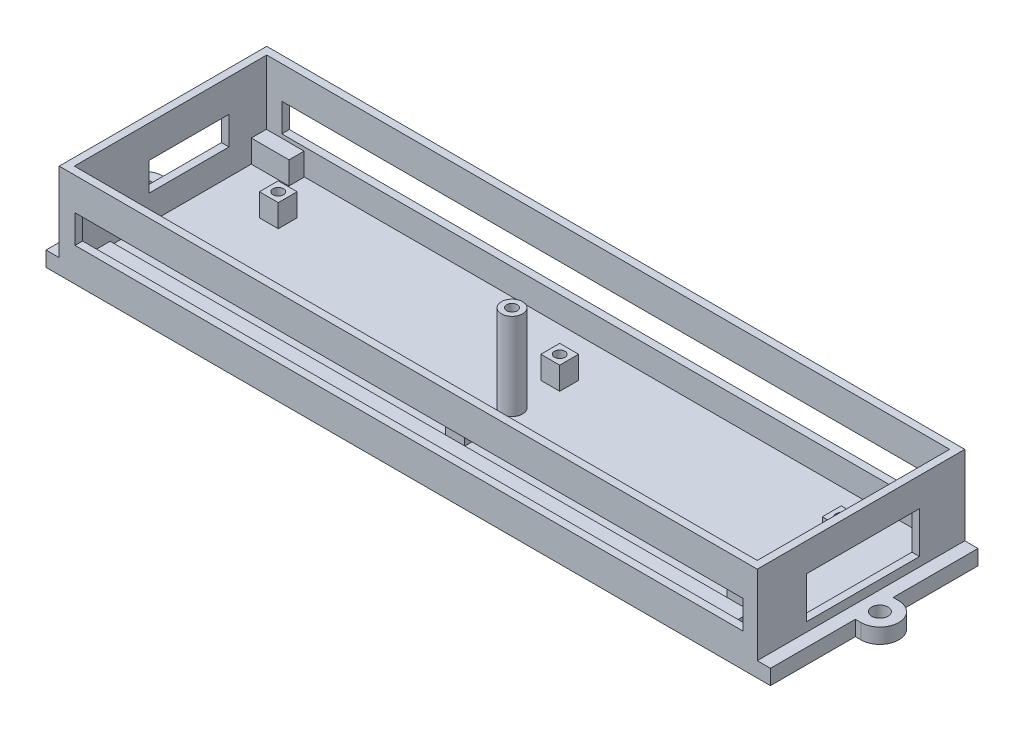
from build123d import *

# Parameters (mm, degrees)
SKETCH_1_W           = 185
SKETCH_1_H           = 55
EXTRUDE_1_DEPTH      = 25
SHELL_1_T            = -2
SKETCH_8_R           = 2.15
EXTRUDE_3_DEPTH      = 4
SKETCH_2_W           = 10
SKETCH_2_H           = 4
SKETCH_2_W_2         = 5
SKETCH_2_H_2         = 5
SKETCH_2_R           = 1.4
SKETCH_2_W_3         = 170
EXTRUDE_4_DEPTH      = 6
SKETCH_2_6_R         = 2.8
SKETCH_2_6_R_2       = 1.4
EXTRUDE_6_DEPTH      = 23
SKETCH_9_W           = 30
SKETCH_9_H           = 11
CUT_EXTRUDE_7_DEPTH  = 5
SKETCH_10_W          = 177
SKETCH_10_H          = 7.5
CUT_EXTRUDE_8_DEPTH  = 5
SKETCH_11_W          = 21.2
SKETCH_11_H          = 7.5
CUT_EXTRUDE_9_DEPTH  = 5
SKETCH_12_W          = 174
SKETCH_12_H          = 7.5
CUT_EXTRUDE_10_DEPTH = 5


with BuildPart() as part:
    # 草图1 → 凸台-拉伸1 (new body)
    with BuildSketch(Plane(origin=(0, 0, 0), x_dir=(1, 0, 0), z_dir=(0, 1, 0))):
        Rectangle(SKETCH_1_W, SKETCH_1_H)
    extrude(amount=EXTRUDE_1_DEPTH)

    # 抽壳1
    shell_1_openings = [part.faces().sort_by_distance(p)[0] for p in [
        (0, 25, 0),
    ]]
    offset(amount=SHELL_1_T, openings=shell_1_openings, kind=Kind.INTERSECTION)

    # 草图8 → 凸台-拉伸3 (add)
    # profile 1 of 2: a face of its own
    with BuildSketch(Plane.XZ):
        with BuildLine():
            Line((-97.5, 5), (-96, 5))
            Line((-96, 5), (-96, 27.5))
            Line((-96, 27.5), (-92.5, 27.5))
            Line((-92.5, 27.5), (-92.5, -27.5))
            Line((-92.5, -27.5), (-96, -27.5))
            Line((-96, -27.5), (-96, -5))
            Line((-96, -5), (-97.5, -5))
            ThreePointArc((-97.5, -5), (-102.5, 0), (-97.5, 5))
        make_face()
        with Locations((-97.5, 0)):
            Circle(SKETCH_8_R, mode=Mode.SUBTRACT)
    # profile 2 of 2: a face of its own
    with BuildSketch(Plane.XZ):
        with BuildLine():
            Line((97.5, -5), (96, -5))
            Line((96, -5), (96, -27.5))
            Line((96, -27.5), (92.5, -27.5))
            Line((92.5, -27.5), (92.5, -5))
            Line((92.5, -5), (92.5, 5))
            Line((92.5, 5), (92.5, 27.5))
            Line((92.5, 27.5), (96, 27.5))
            Line((96, 27.5), (96, 5))
            Line((96, 5), (97.5, 5))
            ThreePointArc((97.5, 5), (102.5, 0), (97.5, -5))
        make_face()
        with Locations((97.5, 0)):
            Circle(SKETCH_8_R, mode=Mode.SUBTRACT)
    extrude(amount=-EXTRUDE_3_DEPTH)

    # 草图2 → 凸台-拉伸4 (add)
    # profile 1 of 7: a face of its own
    with BuildSketch(Plane(origin=(0, 2, 0), x_dir=(1, 0, 0), z_dir=(0, 1, 0))):
        with Locations((-85.5, 23.4)):
            Rectangle(SKETCH_2_W, SKETCH_2_H)
    # profile 2 of 7: a face of its own
    with BuildSketch(Plane(origin=(0, 2, 0), x_dir=(1, 0, 0), z_dir=(0, 1, 0))):
        with Locations((-74.6, 12.65)):
            Rectangle(SKETCH_2_W_2, SKETCH_2_H_2)
        with Locations((-74.6, 12.65)):
            Circle(SKETCH_2_R, mode=Mode.SUBTRACT)
    # profile 3 of 7: a face of its own
    with BuildSketch(Plane(origin=(0, 2, 0), x_dir=(1, 0, 0), z_dir=(0, 1, 0))):
        with Locations((74.6, -12.65)):
            Rectangle(SKETCH_2_W_2, SKETCH_2_H_2)
        with Locations((74.6, -12.65)):
            Circle(SKETCH_2_R, mode=Mode.SUBTRACT)
    # profile 4 of 7: a face of its own
    with BuildSketch(Plane(origin=(0, 2, 0), x_dir=(1, 0, 0), z_dir=(0, 1, 0))):
        with Locations((74.6, 12.65)):
            Rectangle(SKETCH_2_W_2, SKETCH_2_H_2)
        with Locations((74.6, 12.65)):
            Circle(SKETCH_2_R, mode=Mode.SUBTRACT)
    # profile 5 of 7: a face of its own
    with BuildSketch(Plane(origin=(0, 2, 0), x_dir=(1, 0, 0), z_dir=(0, 1, 0))):
        with Locations((0, -12.65)):
            Rectangle(SKETCH_2_W_2, SKETCH_2_H_2)
        with Locations((0, -12.65)):
            Circle(SKETCH_2_R, mode=Mode.SUBTRACT)
    # profile 6 of 7: a face of its own
    with BuildSketch(Plane(origin=(0, 2, 0), x_dir=(1, 0, 0), z_dir=(0, 1, 0))):
        with Locations((0, 12.65)):
            Rectangle(SKETCH_2_W_2, SKETCH_2_H_2)
        with Locations((0, 12.65)):
            Circle(SKETCH_2_R, mode=Mode.SUBTRACT)
    # profile 7 of 7: a face of its own
    with BuildSketch(Plane(origin=(0, 2, 0), x_dir=(1, 0, 0), z_dir=(0, 1, 0))):
        with Locations((-0.5, -23.002466961)):
            Rectangle(SKETCH_2_W_3, SKETCH_2_H)
    extrude(amount=EXTRUDE_4_DEPTH)

    # 草图2<6> → 凸台-拉伸6 (add)
    with BuildSketch(Plane(origin=(0, 2, 0), x_dir=(1, 0, 0), z_dir=(0, 1, 0))):
        Circle(SKETCH_2_6_R)
        Circle(SKETCH_2_6_R_2, mode=Mode.SUBTRACT)
    extrude(amount=EXTRUDE_6_DEPTH)

    # 草图9 → 切除-拉伸7 (cut)
    with BuildSketch(Plane(origin=(92.5, 0, 0), x_dir=(0, 0, -1), z_dir=(1, 0, 0))):
        with Locations((0.5, 11.9)):
            Rectangle(SKETCH_9_W, SKETCH_9_H)
    extrude(amount=-CUT_EXTRUDE_7_DEPTH, mode=Mode.SUBTRACT)

    # 草图10 → 切除-拉伸8 (cut)
    with BuildSketch(Plane.XY.offset(27.5)):
        with Locations((0.2, 12.65)):
            Rectangle(SKETCH_10_W, SKETCH_10_H)
    extrude(amount=-CUT_EXTRUDE_8_DEPTH, mode=Mode.SUBTRACT)

    # 草图11 → 切除-拉伸9 (cut)
    with BuildSketch(Plane.ZY.offset(92.5)):
        with Locations((-4.9, 12.65)):
            Rectangle(SKETCH_11_W, SKETCH_11_H)
    extrude(amount=-CUT_EXTRUDE_9_DEPTH, mode=Mode.SUBTRACT)

    # 草图12 → 切除-拉伸10 (cut)
    with BuildSketch(Plane(origin=(0, 0, -27.5), x_dir=(-1, 0, 0), z_dir=(0, 0, -1))):
        with Locations((-0.5, 12.65)):
            Rectangle(SKETCH_12_W, SKETCH_12_H)
    extrude(amount=-CUT_EXTRUDE_10_DEPTH, mode=Mode.SUBTRACT)


solid = part.part
